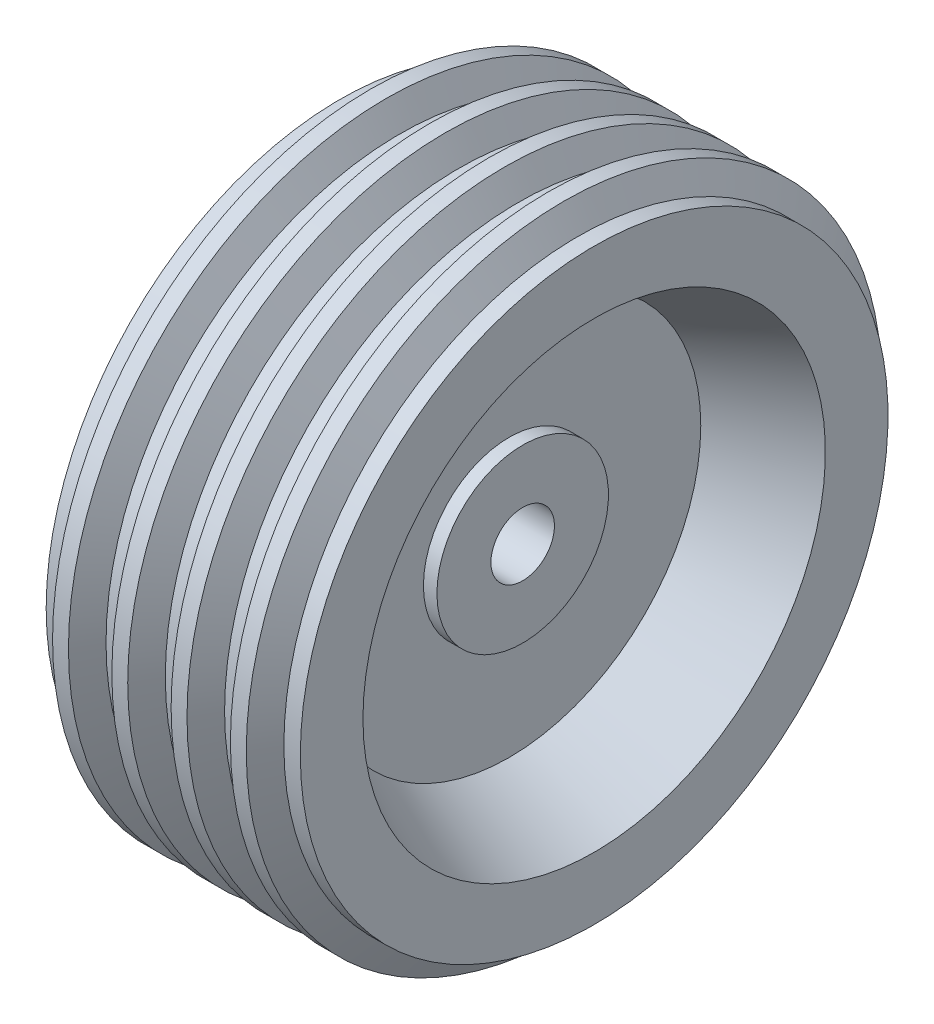
from build123d import *


with BuildPart() as part:
    # Sketch2 → Revolve1 (revolve)
    with BuildSketch(Plane.XY):
        Polygon((-35, 20), (35, 20), (35, 54), (26.5, 54), (26.5, 120.622540289), (80, 145.57), (80, 185), (69.641016151, 185), (60.980762114, 200), (50.980762114, 200), (42.320508076, 185), (32.320508076, 185), (23.660254038, 200), (13.660254038, 200), (5, 185), (-5, 185), (-13.660254038, 200), (-23.660254038, 200), (-32.320508076, 185), (-42.320508076, 185), (-50.980762114, 200), (-60.980762114, 200), (-69.641016151, 185), (-80, 185), (-80, 145.57), (-26.5, 120.622540289), (-26.5, 54), (-35, 54), align=None)
    revolve(axis=Axis((-192.57069662, 0, 0), (1, 0, 0)))


solid = part.part
